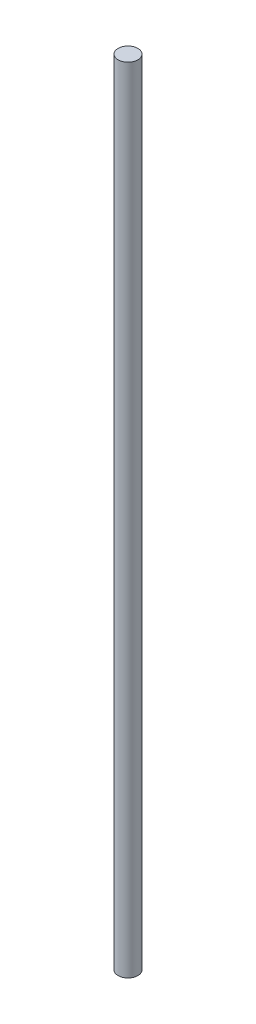
from build123d import *

# Parameters (mm, degrees)
SKETCH1_R           = 5
BOSS_EXTRUDE1_DEPTH = 200


with BuildPart() as part:
    # Sketch1 → Boss-Extrude1 (new body, symmetric)
    with BuildSketch(Plane(origin=(0, 0, 0), x_dir=(1, 0, 0), z_dir=(0, 1, 0))):
        Circle(SKETCH1_R)
    extrude(amount=BOSS_EXTRUDE1_DEPTH, both=True)


solid = part.part
